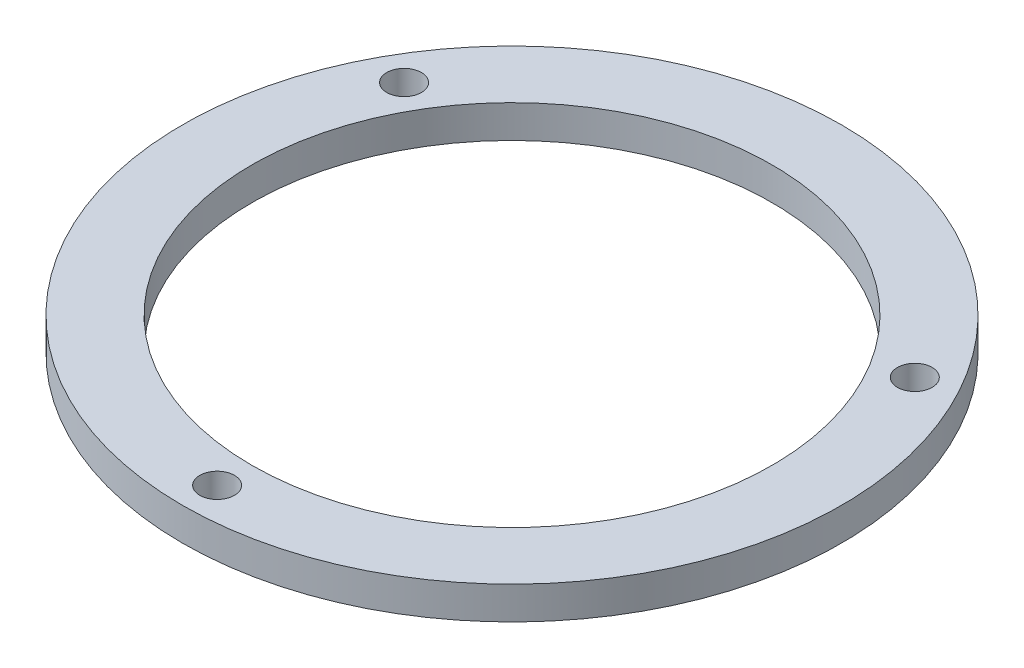
from build123d import *

# Parameters (mm, degrees)
SKETCH1_R           = 60.3504
SKETCH1_R_2         = 47.6504
SKETCH1_R_3         = 3.175
BOSS_EXTRUDE1_DEPTH = 6


with BuildPart() as part:
    # Sketch1 → Boss-Extrude1 (new body)
    with BuildSketch(Plane(origin=(0, 0, 0), x_dir=(1, 0, 0), z_dir=(0, 1, 0))):
        Circle(SKETCH1_R)
        Circle(SKETCH1_R_2, mode=Mode.SUBTRACT)
        with Locations((0, -54.0004)):
            Circle(SKETCH1_R_3, mode=Mode.SUBTRACT)
        with Locations((-46.765718215, 27.0002)):
            Circle(SKETCH1_R_3, mode=Mode.SUBTRACT)
        with Locations((46.765718215, 27.0002)):
            Circle(SKETCH1_R_3, mode=Mode.SUBTRACT)
    extrude(amount=BOSS_EXTRUDE1_DEPTH)


solid = part.part
